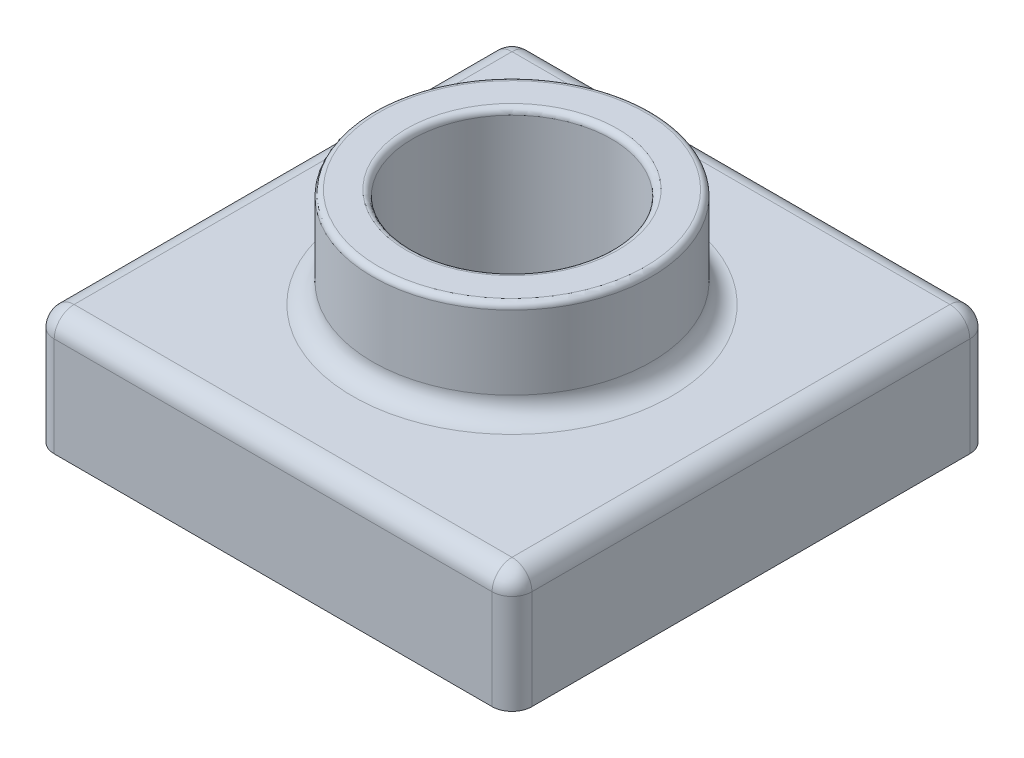
from build123d import *

# Parameters (mm, degrees)
SKETCH1_W           = 120
SKETCH1_H           = 120
BOSS_EXTRUDE1_DEPTH = 30
SKETCH2_R           = 35
BOSS_EXTRUDE2_DEPTH = 25
SKETCH3_R           = 25
CUT_EXTRUDE1_DEPTH  = 102.118742081
FILLET1_R           = 5
FILLET2_R           = 1.5
SHELL1_T            = -2


with BuildPart() as part:
    # Sketch1 → Boss-Extrude1 (new body)
    with BuildSketch(Plane(origin=(0, 0, 0), x_dir=(1, 0, 0), z_dir=(0, 1, 0))):
        Rectangle(SKETCH1_W, SKETCH1_H)
    extrude(amount=BOSS_EXTRUDE1_DEPTH)

    # Sketch2 → Boss-Extrude2 (add)
    with BuildSketch(Plane(origin=(0, 30, 0), x_dir=(1, 0, 0), z_dir=(0, 1, 0))):
        with Locations(Location((0, 0, 0), (0, 0, 270))):
            Circle(SKETCH2_R)
    extrude(amount=BOSS_EXTRUDE2_DEPTH)

    # Sketch3 → Cut-Extrude1 (cut, through all)
    with BuildSketch(Plane(origin=(0, 55, 0), x_dir=(1, 0, 0), z_dir=(0, 1, 0))):
        with Locations(Location((0, 0, 0), (0, 0, 270))):
            Circle(SKETCH3_R)
    extrude(amount=-CUT_EXTRUDE1_DEPTH, mode=Mode.SUBTRACT)

    # Fillet1
    fillet1_edges = [part.edges().sort_by_distance(p)[0] for p in [
        (-60, 30, 0),
        (0, 30, -35),
        (0, 30, 60),
        (60, 30, 0),
        (60, 15, 60),
        (-60, 15, 60),
        (-60, 15, -60),
        (60, 15, -60),
        (0, 30, -60),
    ]]
    fillet(fillet1_edges, radius=FILLET1_R)

    # Fillet2
    fillet2_edges = [part.edges().sort_by_distance(p)[0] for p in [
        (0, 55, -35),
        (0, 55, -25),
    ]]
    fillet(fillet2_edges, radius=FILLET2_R)

    # Shell1
    shell1_openings = [part.faces().sort_by_distance(p)[0] for p in [
        (0, 0, 58.302943725),
    ]]
    offset(amount=SHELL1_T, openings=shell1_openings, kind=Kind.INTERSECTION)


solid = part.part
